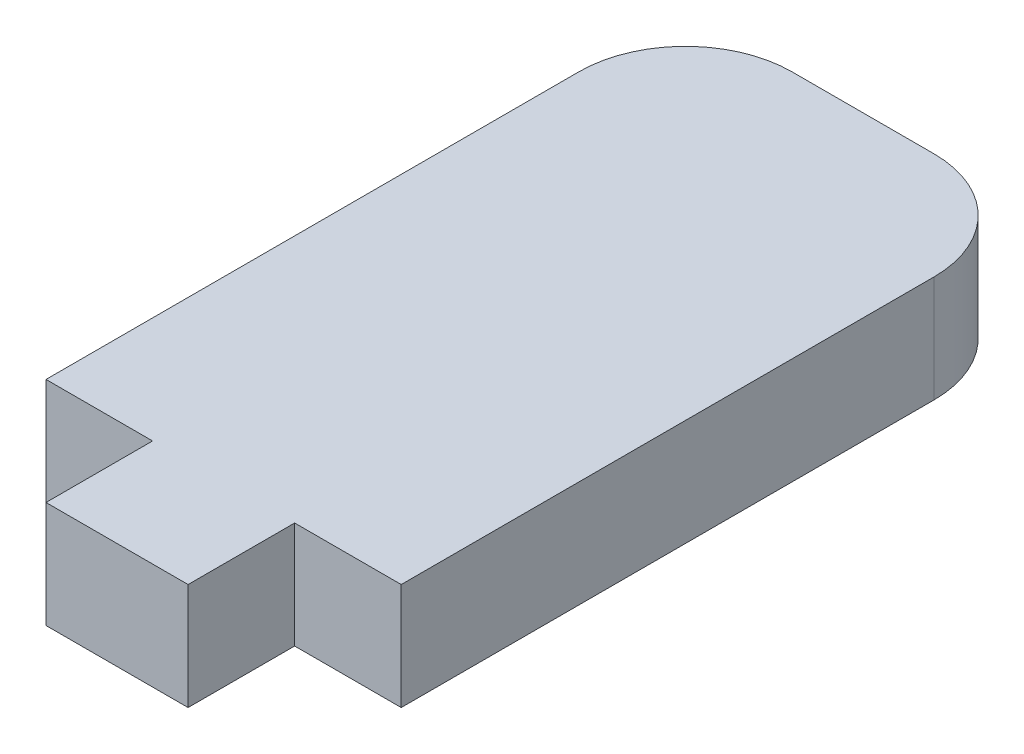
from build123d import *

# Parameters (mm, degrees)
BOSS_EXTRUDE4_DEPTH = 1.5
SKETCH8_W           = 4
SKETCH8_H           = 3
BOSS_EXTRUDE5_DEPTH = 1.5


with BuildPart() as part:
    # Sketch6 → Boss-Extrude4 (new body, symmetric)
    with BuildSketch(Plane(origin=(0, 0, 0), x_dir=(1, 0, 0), z_dir=(0, 1, 0))):
        with BuildLine():
            Line((-2, 10.5), (2, 10.5))
            ThreePointArc((2, 10.5), (4.121320344, 9.621320344), (5, 7.5))
            Line((5, 7.5), (5, -7.5))
            Line((5, -7.5), (-5, -7.5))
            Line((-5, -7.5), (-5, 7.5))
            ThreePointArc((-5, 7.5), (-4.121320344, 9.621320344), (-2, 10.5))
        make_face()
    extrude(amount=BOSS_EXTRUDE4_DEPTH, both=True)

    # Sketch8 → Boss-Extrude5 (add, symmetric)
    with BuildSketch(Plane(origin=(0, 0, 0), x_dir=(1, 0, 0), z_dir=(0, 1, 0))):
        with Locations((0, -9)):
            Rectangle(SKETCH8_W, SKETCH8_H)
    extrude(amount=BOSS_EXTRUDE5_DEPTH, both=True)


solid = part.part
